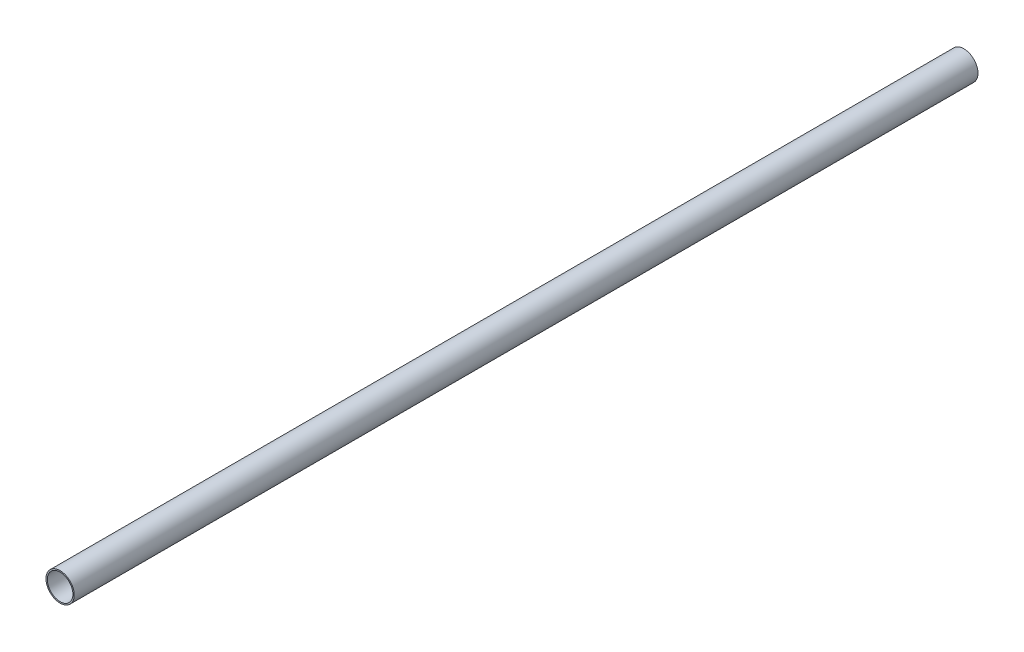
from build123d import *

# Parameters (mm, degrees)
SKETCH1_R           = 4.7625
SKETCH1_R_2         = 4.318
BOSS_EXTRUDE1_DEPTH = 304.8


with BuildPart() as part:
    # Sketch1 → Boss-Extrude1 (new body)
    with BuildSketch(Plane.XY):
        Circle(SKETCH1_R)
        Circle(SKETCH1_R_2, mode=Mode.SUBTRACT)
    extrude(amount=BOSS_EXTRUDE1_DEPTH)


solid = part.part
